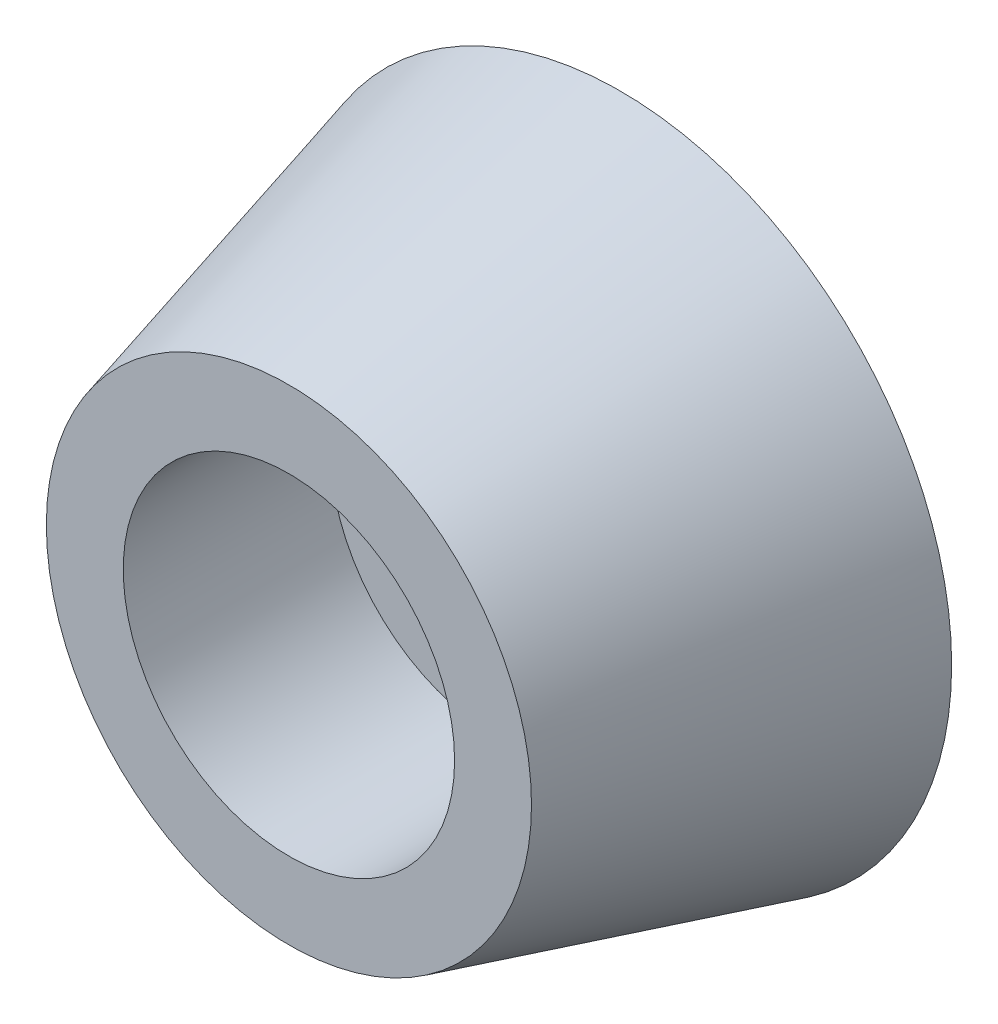
from build123d import *

# Parameters (mm, degrees)
SKETCH1_R           = 6.35
BOSS_EXTRUDE1_DEPTH = 6.35
BOSS_EXTRUDE1_TAPER = 15
SKETCH2_R           = 3.175
CUT_EXTRUDE1_DEPTH  = 3.96875
SKETCH3_R           = 1.5875
CUT_EXTRUDE2_DEPTH  = 3.38125


with BuildPart() as part:
    # Sketch1 → Boss-Extrude1 (new body)
    with BuildSketch(Plane.XY):
        Circle(SKETCH1_R)
    extrude(amount=BOSS_EXTRUDE1_DEPTH, taper=BOSS_EXTRUDE1_TAPER)

    # Sketch2 → Cut-Extrude1 (cut)
    with BuildSketch(Plane.XY.offset(6.35)):
        Circle(SKETCH2_R)
    extrude(amount=-CUT_EXTRUDE1_DEPTH, mode=Mode.SUBTRACT)

    # Sketch3 → Cut-Extrude2 (cut, through all)
    with BuildSketch(Plane.XY.offset(2.38125)):
        Circle(SKETCH3_R)
    extrude(amount=-CUT_EXTRUDE2_DEPTH, mode=Mode.SUBTRACT)


solid = part.part
